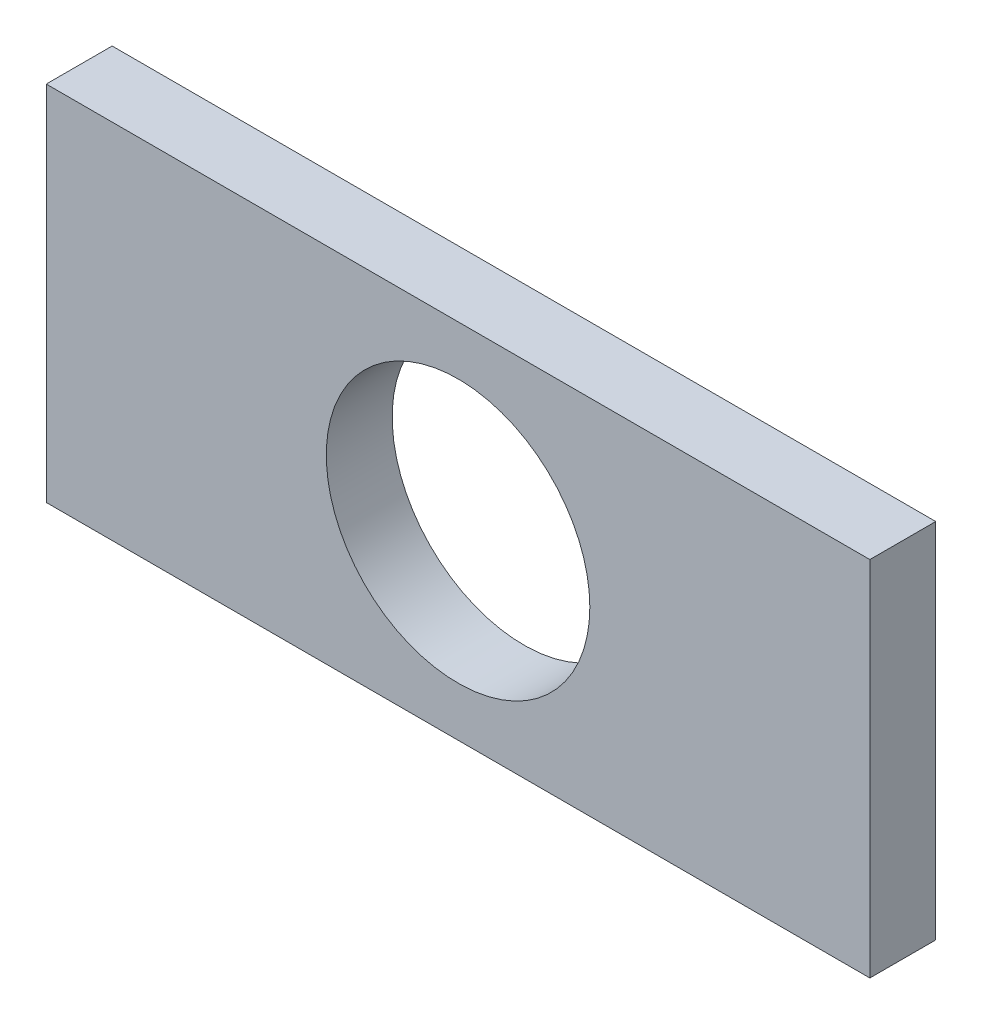
from build123d import *

# Parameters (mm, degrees)
SKETCH_1_W      = 37.5
SKETCH_1_H      = 16.5
SKETCH_1_R      = 6
EXTRUDE_1_DEPTH = 3


with BuildPart() as part:
    # 草图1 → 凸台-拉伸1 (new body)
    with BuildSketch(Plane.XY):
        Rectangle(SKETCH_1_W, SKETCH_1_H)
        Circle(SKETCH_1_R, mode=Mode.SUBTRACT)
    extrude(amount=EXTRUDE_1_DEPTH)


solid = part.part
